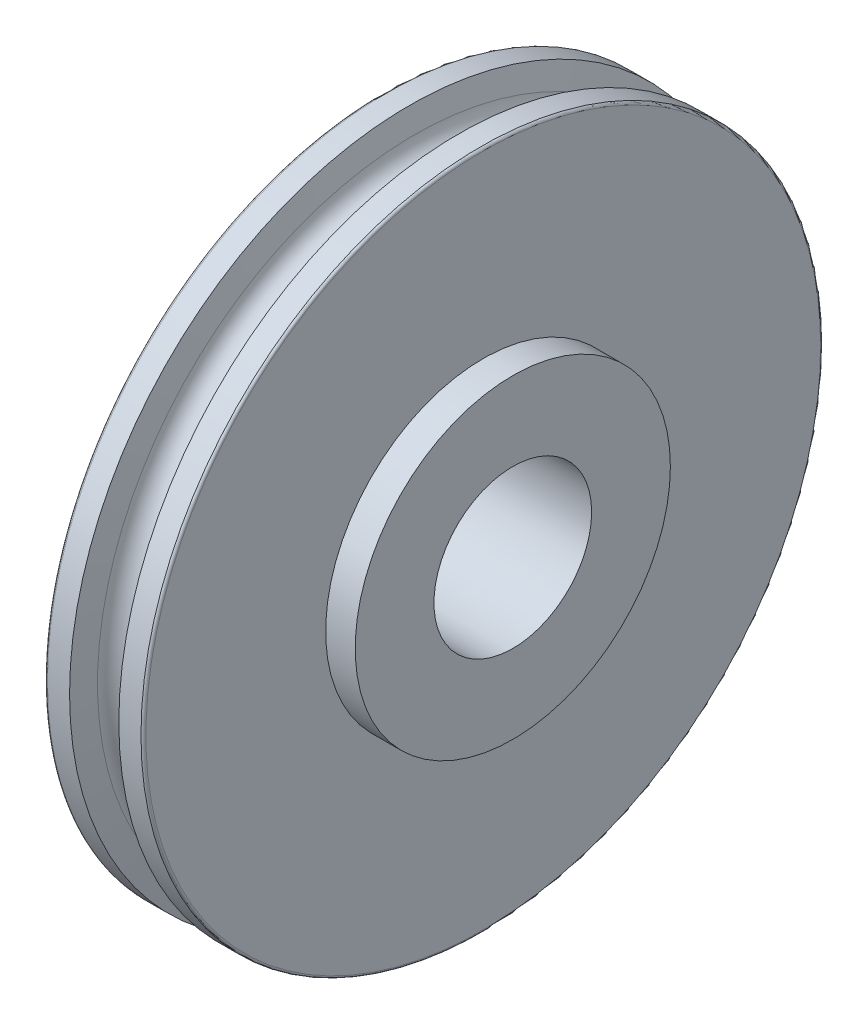
from build123d import *

# Parameters (mm, degrees)
SKETCH2_R          = 25.4127
CUT_EXTRUDE1_DEPTH = 51.8


with BuildPart() as part:
    # Sketch1 → Revolve1 (revolve)
    with BuildSketch(Plane.XY, mode=Mode.PRIVATE) as revolve1_sk:
        with BuildLine():
            Line((-15.875, 50.8), (-15.875, 108.74375))
            ThreePointArc((-15.875, 108.74375), (-15.642516008, 109.305016008), (-15.08125, 109.5375))
            Line((-15.08125, 109.5375), (-7.9375, 109.5375))
            Line((-7.9375, 109.5375), (-6.271845407, 102.194295494))
            ThreePointArc((-6.271845407, 102.194295494), (0, 96.8375), (6.271845407, 102.194295494))
            Line((6.271845407, 102.194295494), (7.9375, 109.5375))
            Line((7.9375, 109.5375), (15.08125, 109.5375))
            ThreePointArc((15.08125, 109.5375), (15.642516008, 109.305016008), (15.875, 108.74375))
            Line((15.875, 108.74375), (15.875, 50.8))
            Line((15.875, 50.8), (25.4, 50.8))
            Line((25.4, 50.8), (25.4, 0))
            Line((25.4, 0), (-25.4, 0))
            Line((-25.4, 0), (-25.4, 50.8))
            Line((-25.4, 50.8), (-15.875, 50.8))
        make_face()
    revolve(revolve1_sk.sketch.rotate(Axis((25.4, 0, 0), (-1, 0, 0)), 90), axis=Axis((25.4, 0, 0), (-1, 0, 0)))  # turned: the seam where the file's is

    # Sketch2 → Cut-Extrude1 (cut, through all)
    with BuildSketch(Plane(origin=(25.4, 0, 0), x_dir=(0, 0, -1), z_dir=(1, 0, 0))):
        Circle(SKETCH2_R)
    extrude(amount=-CUT_EXTRUDE1_DEPTH, mode=Mode.SUBTRACT)


solid = part.part
